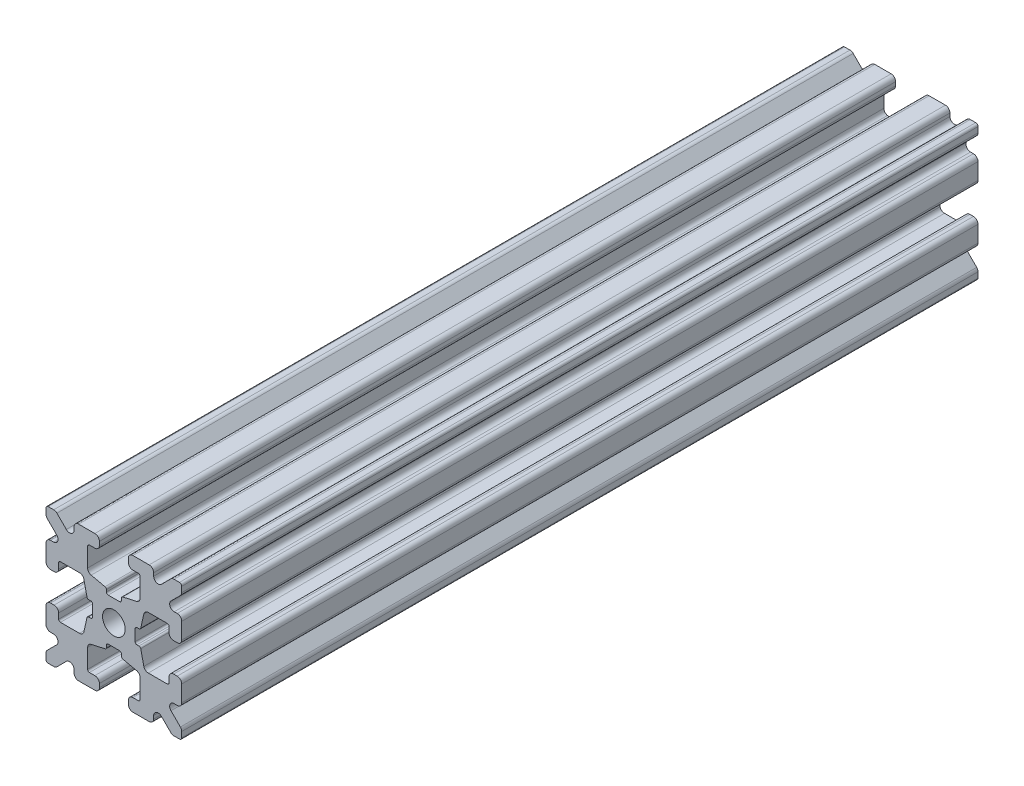
from build123d import *

# Parameters (mm, degrees)
SKETCH1_W           = 15
SKETCH1_H           = 15
SKETCH1_R           = 1.25
BOSS_EXTRUDE1_DEPTH = 44
FILLET1_R           = 0.25
CUT_EXTRUDE1_DEPTH  = 89
CUT_EXTRUDE3_DEPTH  = 89
FILLET3_R           = 0.5
FILLET4_R           = 0.5
FILLET5_R           = 3
FILLET6_R           = 0.2
CUT_EXTRUDE4_DEPTH  = 89
FILLET8_R           = 0.5
SKETCH6_W           = 5.1529354
SKETCH6_H           = 1.651
SKETCH6_W_2         = 1.651
SKETCH6_H_2         = 5.1529354
CUT_EXTRUDE5_DEPTH  = 89
FILLET10_R          = 0.2


with BuildPart() as part:
    # Sketch1 → Boss-Extrude1 (new body, symmetric)
    with BuildSketch(Plane.XY):
        Rectangle(SKETCH1_W, SKETCH1_H)
        Circle(SKETCH1_R, mode=Mode.SUBTRACT)
    extrude(amount=BOSS_EXTRUDE1_DEPTH, both=True)

    # Fillet1
    fillet1_edges = [part.edges().sort_by_distance(p)[0] for p in [
        (7.5, -7.5, 0),
        (-7.5, -7.5, 0),
        (-7.5, 7.5, 0),
        (7.5, 7.5, 0),
    ]]
    fillet(fillet1_edges, radius=FILLET1_R)

    # Sketch2 → Cut-Extrude1 (cut, through all)
    with BuildSketch(Plane.XY.offset(44)):
        Polygon((-7.5, 1.6), (-6.1, 1.6), (-6.1, 2.9), (-3.4, 2.9), (-3.4, -2.9), (-6.1, -2.9), (-6.1, -1.6), (-7.5, -1.6), align=None)
        Polygon((2.9, 6.1), (1.6, 6.1), (1.6, 7.5), (-1.6, 7.5), (-1.6, 6.1), (-2.9, 6.1), (-2.9, 3.4), (2.9, 3.4), align=None)
        Polygon((-1.6, -7.5), (-1.6, -6.1), (-2.9, -6.1), (-2.9, -3.4), (2.9, -3.4), (2.9, -6.1), (1.6, -6.1), (1.6, -7.5), align=None)
        Polygon((6.1, -2.9), (6.1, -1.6), (7.5, -1.6), (7.5, 1.6), (6.1, 1.6), (6.1, 2.9), (3.4, 2.9), (3.4, -2.9), align=None)
    extrude(amount=-CUT_EXTRUDE1_DEPTH, mode=Mode.SUBTRACT)

    # Sketch4 → Cut-Extrude3 (cut, through all)
    with BuildSketch(Plane.XY.offset(44)):
        Polygon((-3.4, 2.9), (-2.75, 0), (-3.4, -2.9), align=None)
        Polygon((-2.9, 3.4), (0, 2.75), (2.9, 3.4), align=None)
        Polygon((3.4, 2.9), (2.75, 0), (3.4, -2.9), align=None)
        Polygon((-2.9, -3.4), (0, -2.75), (2.9, -3.4), align=None)
    extrude(amount=-CUT_EXTRUDE3_DEPTH, mode=Mode.SUBTRACT)

    # Fillet3
    fillet3_edges = [part.edges().sort_by_distance(p)[0] for p in [
        (1.6, -7.5, 0),
        (-1.6, -7.5, 0),
        (-1.6, -6.1, 0),
        (1.6, -6.1, 0),
        (6.1, 1.6, 0),
        (7.5, 1.6, 0),
        (7.5, -1.6, 0),
        (6.1, -1.6, 0),
        (-7.5, -1.6, 0),
        (-7.5, 1.6, 0),
        (-6.1, 1.6, 0),
        (-6.1, -1.6, 0),
        (-1.6, 6.1, 0),
        (-1.6, 7.5, 0),
        (1.6, 7.5, 0),
        (1.6, 6.1, 0),
    ]]
    fillet(fillet3_edges, radius=FILLET3_R)

    # Fillet4
    fillet4_edges = [part.edges().sort_by_distance(p)[0] for p in [
        (-2.9, -3.4, 0),
        (2.9, -3.4, 0),
        (3.4, -2.9, 0),
        (3.4, 2.9, 0),
        (-3.4, 2.9, 0),
        (-3.4, -2.9, 0),
        (2.9, 3.4, 0),
        (-2.9, 3.4, 0),
    ]]
    fillet(fillet4_edges, radius=FILLET4_R)

    # Fillet5
    fillet5_edges = [part.edges().sort_by_distance(p)[0] for p in [
        (-2.75, 0, 0),
        (0, 2.75, 0),
        (2.75, 0, 0),
        (0, -2.75, 0),
    ]]
    fillet(fillet5_edges, radius=FILLET5_R)

    # Fillet6
    fillet6_edges = [part.edges().sort_by_distance(p)[0] for p in [
        (-2.9, -6.1, 0),
        (2.9, -6.1, 0),
        (6.1, -2.9, 0),
        (6.1, 2.9, 0),
        (-6.1, 2.9, 0),
        (-6.1, -2.9, 0),
        (2.9, 6.1, 0),
        (-2.9, 6.1, 0),
    ]]
    fillet(fillet6_edges, radius=FILLET6_R)

    # Sketch5 → Cut-Extrude4 (cut, through all)
    with BuildSketch(Plane.XY.offset(44)):
        Polygon((-7.5, 6.439339828), (-5.460660172, 4.4), (-7.5, 4.4), align=None)
        Polygon((-6.439339828, 7.5), (-4.4, 5.460660172), (-4.4, 7.5), align=None)
        Polygon((4.4, 7.5), (6.439339828, 7.5), (4.4, 5.460660172), align=None)
        Polygon((7.5, 6.439339828), (7.5, 4.4), (5.460660172, 4.4), align=None)
        Polygon((7.5, -6.439339828), (5.460660172, -4.4), (7.5, -4.4), align=None)
        Polygon((6.439339828, -7.5), (4.4, -5.460660172), (4.4, -7.5), align=None)
        Polygon((-4.4, -7.5), (-6.439339828, -7.5), (-4.4, -5.460660172), align=None)
        Polygon((-7.5, -6.439339828), (-7.5, -4.4), (-5.460660172, -4.4), align=None)
    extrude(amount=-CUT_EXTRUDE4_DEPTH, mode=Mode.SUBTRACT)

    # Fillet8
    fillet8_edges = [part.edges().sort_by_distance(p)[0] for p in [
        (-7.5, 4.4, 0),
        (-7.5, 6.439339828, 0),
        (-5.460660172, 4.4, 0),
        (7.5, -4.4, 0),
        (7.5, -6.439339828, 0),
        (5.460660172, -4.4, 0),
        (5.460660172, 4.4, 0),
        (7.5, 6.439339828, 0),
        (7.5, 4.4, 0),
        (-4.4, 7.5, 0),
        (-4.4, 5.460660172, 0),
        (-6.439339828, 7.5, 0),
        (-5.460660172, -4.4, 0),
        (-7.5, -6.439339828, 0),
        (-7.5, -4.4, 0),
        (4.4, 5.460660172, 0),
        (4.4, 7.5, 0),
        (6.439339828, 7.5, 0),
        (6.439339828, -7.5, 0),
        (4.4, -7.5, 0),
        (4.4, -5.460660172, 0),
        (-6.439339828, -7.5, 0),
        (-4.4, -5.460660172, 0),
        (-4.4, -7.5, 0),
    ]]
    fillet(fillet8_edges, radius=FILLET8_R)

    # Sketch6 → Cut-Extrude5 (cut, through all)
    with BuildSketch(Plane.XY.offset(44)):
        with Locations((4.9235323, 0)):
            Rectangle(SKETCH6_W, SKETCH6_H)
        with Locations((0, -4.9235323)):
            Rectangle(SKETCH6_W_2, SKETCH6_H_2)
        with Locations((-4.9235323, 0)):
            Rectangle(SKETCH6_W, SKETCH6_H)
        with Locations((0, 4.9235323)):
            Rectangle(SKETCH6_W_2, SKETCH6_H_2)
    extrude(amount=-CUT_EXTRUDE5_DEPTH, mode=Mode.SUBTRACT)

    # Fillet10
    fillet10_edges = [part.edges().sort_by_distance(p)[0] for p in [
        (0.8255, -2.935025862, 0),
        (-0.8255, -2.935025862, 0),
        (0.8255, -2.3470646, 0),
        (-0.8255, -2.3470646, 0),
        (2.935025862, 0.8255, 0),
        (2.935025862, -0.8255, 0),
        (2.3470646, 0.8255, 0),
        (2.3470646, -0.8255, 0),
        (-2.935025862, -0.8255, 0),
        (-2.935025862, 0.8255, 0),
        (-2.3470646, -0.8255, 0),
        (-2.3470646, 0.8255, 0),
        (-0.8255, 2.935025862, 0),
        (0.8255, 2.935025862, 0),
        (-0.8255, 2.3470646, 0),
        (0.8255, 2.3470646, 0),
    ]]
    fillet(fillet10_edges, radius=FILLET10_R)


solid = part.part
